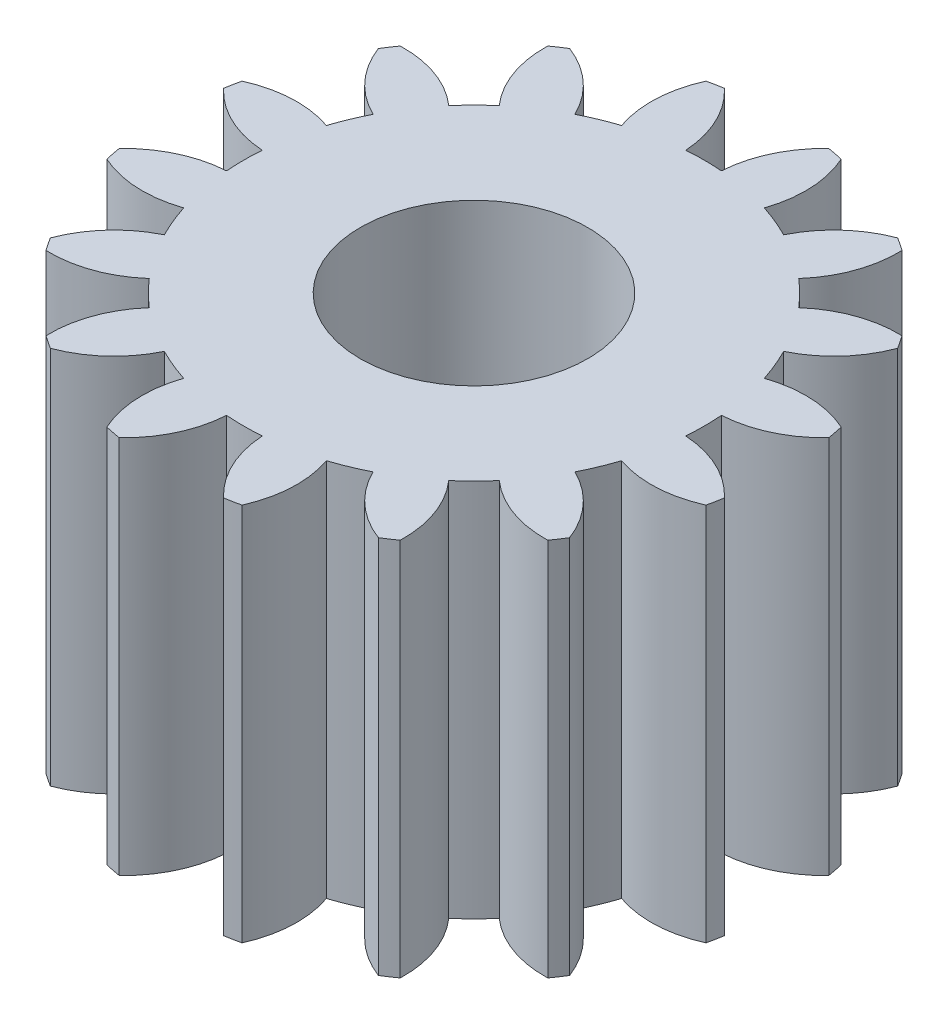
from build123d import *

# Parameters (mm, degrees)
BOSS_EXTRUDE1_DEPTH = 10
SKETCH2_R           = 3
CUT_EXTRUDE1_DEPTH  = 10


with BuildPart() as part:
    # Sketch1 → Boss-Extrude1 (new body)
    with BuildSketch(Plane(origin=(0, 0, 0), x_dir=(1, 0, 0), z_dir=(0, 1, 0))):
        with BuildLine():
            ThreePointArc((-7.982172642, 1.3765609), (-7.105660658, 0.739320543), (-6.05570223, 0.47111199))
            ThreePointArc((-6.05570223, 0.47111199), (-6.074, 0), (-6.05570223, -0.47111199))
            ThreePointArc((-6.05570223, -0.47111199), (-7.105660658, -0.739320543), (-7.982172642, -1.3765609))
            ThreePointArc((-7.982172642, -1.3765609), (-7.944360771, -1.580231608), (-7.901352979, -1.782868784))
            ThreePointArc((-7.901352979, -1.782868784), (-6.84770017, -2.036175492), (-5.775026098, -1.882166189))
            ThreePointArc((-5.775026098, -1.882166189), (-5.61164428, -2.324419168), (-5.414452591, -2.75266764))
            ThreePointArc((-5.414452591, -2.75266764), (-6.281848724, -3.402261728), (-6.847778879, -4.326421665))
            ThreePointArc((-6.847778879, -4.326421665), (-6.73490386, -4.500118887), (-6.617623951, -4.670872857))
            ThreePointArc((-6.617623951, -4.670872857), (-5.547239406, -4.501682267), (-4.615154594, -3.948901628))
            ThreePointArc((-4.615154594, -3.948901628), (-4.294966589, -4.294966589), (-3.948901628, -4.615154594))
            ThreePointArc((-3.948901628, -4.615154594), (-4.501682267, -5.547239406), (-4.670872857, -6.617623951))
            ThreePointArc((-4.670872857, -6.617623951), (-4.500118887, -6.73490386), (-4.326421665, -6.847778879))
            ThreePointArc((-4.326421665, -6.847778879), (-3.402261728, -6.281848724), (-2.75266764, -5.414452591))
            ThreePointArc((-2.75266764, -5.414452591), (-2.324419168, -5.61164428), (-1.882166189, -5.775026098))
            ThreePointArc((-1.882166189, -5.775026098), (-2.036175492, -6.84770017), (-1.782868784, -7.901352979))
            ThreePointArc((-1.782868784, -7.901352979), (-1.580231608, -7.944360771), (-1.3765609, -7.982172642))
            ThreePointArc((-1.3765609, -7.982172642), (-0.739320543, -7.105660658), (-0.47111199, -6.05570223))
            ThreePointArc((-0.47111199, -6.05570223), (0, -6.074), (0.47111199, -6.05570223))
            ThreePointArc((0.47111199, -6.05570223), (0.739320543, -7.105660658), (1.3765609, -7.982172642))
            ThreePointArc((1.3765609, -7.982172642), (1.580231608, -7.944360771), (1.782868784, -7.901352979))
            ThreePointArc((1.782868784, -7.901352979), (2.036175492, -6.84770017), (1.882166189, -5.775026098))
            ThreePointArc((1.882166189, -5.775026098), (2.324419168, -5.61164428), (2.75266764, -5.414452591))
            ThreePointArc((2.75266764, -5.414452591), (3.402261728, -6.281848724), (4.326421665, -6.847778879))
            ThreePointArc((4.326421665, -6.847778879), (4.500118887, -6.73490386), (4.670872857, -6.617623951))
            ThreePointArc((4.670872857, -6.617623951), (4.501682267, -5.547239406), (3.948901628, -4.615154594))
            ThreePointArc((3.948901628, -4.615154594), (4.294966589, -4.294966589), (4.615154594, -3.948901628))
            ThreePointArc((4.615154594, -3.948901628), (5.547239406, -4.501682267), (6.617623951, -4.670872857))
            ThreePointArc((6.617623951, -4.670872857), (6.73490386, -4.500118887), (6.847778879, -4.326421665))
            ThreePointArc((6.847778879, -4.326421665), (6.281848724, -3.402261728), (5.414452591, -2.75266764))
            ThreePointArc((5.414452591, -2.75266764), (5.61164428, -2.324419168), (5.775026098, -1.882166189))
            ThreePointArc((5.775026098, -1.882166189), (6.84770017, -2.036175492), (7.901352979, -1.782868784))
            ThreePointArc((7.901352979, -1.782868784), (7.944360771, -1.580231608), (7.982172642, -1.3765609))
            ThreePointArc((7.982172642, -1.3765609), (7.105660658, -0.739320543), (6.05570223, -0.47111199))
            ThreePointArc((6.05570223, -0.47111199), (6.074, 0), (6.05570223, 0.47111199))
            ThreePointArc((6.05570223, 0.47111199), (7.105660658, 0.739320543), (7.982172642, 1.3765609))
            ThreePointArc((7.982172642, 1.3765609), (7.944360771, 1.580231608), (7.901352979, 1.782868784))
            ThreePointArc((7.901352979, 1.782868784), (6.84770017, 2.036175492), (5.775026098, 1.882166189))
            ThreePointArc((5.775026098, 1.882166189), (5.61164428, 2.324419168), (5.414452591, 2.75266764))
            ThreePointArc((5.414452591, 2.75266764), (6.281848724, 3.402261728), (6.847778879, 4.326421665))
            ThreePointArc((6.847778879, 4.326421665), (6.73490386, 4.500118887), (6.617623951, 4.670872857))
            ThreePointArc((6.617623951, 4.670872857), (5.547239406, 4.501682267), (4.615154594, 3.948901628))
            ThreePointArc((4.615154594, 3.948901628), (4.294966589, 4.294966589), (3.948901628, 4.615154594))
            ThreePointArc((3.948901628, 4.615154594), (4.501682267, 5.547239406), (4.670872857, 6.617623951))
            ThreePointArc((4.670872857, 6.617623951), (4.500118887, 6.73490386), (4.326421665, 6.847778879))
            ThreePointArc((4.326421665, 6.847778879), (3.402261728, 6.281848724), (2.75266764, 5.414452591))
            ThreePointArc((2.75266764, 5.414452591), (2.324419168, 5.61164428), (1.882166189, 5.775026098))
            ThreePointArc((1.882166189, 5.775026098), (2.036175492, 6.84770017), (1.782868784, 7.901352979))
            ThreePointArc((1.782868784, 7.901352979), (1.580231608, 7.944360771), (1.3765609, 7.982172642))
            ThreePointArc((1.3765609, 7.982172642), (0.739320543, 7.105660658), (0.47111199, 6.05570223))
            ThreePointArc((0.47111199, 6.05570223), (0, 6.074), (-0.47111199, 6.05570223))
            ThreePointArc((-0.47111199, 6.05570223), (-0.739320543, 7.105660658), (-1.3765609, 7.982172642))
            ThreePointArc((-1.3765609, 7.982172642), (-1.580231608, 7.944360771), (-1.782868784, 7.901352979))
            ThreePointArc((-1.782868784, 7.901352979), (-2.036175492, 6.84770017), (-1.882166189, 5.775026098))
            ThreePointArc((-1.882166189, 5.775026098), (-2.324419168, 5.61164428), (-2.75266764, 5.414452591))
            ThreePointArc((-2.75266764, 5.414452591), (-3.402261728, 6.281848724), (-4.326421665, 6.847778879))
            ThreePointArc((-4.326421665, 6.847778879), (-4.500118887, 6.73490386), (-4.670872857, 6.617623951))
            ThreePointArc((-4.670872857, 6.617623951), (-4.501682267, 5.547239406), (-3.948901628, 4.615154594))
            ThreePointArc((-3.948901628, 4.615154594), (-4.294966589, 4.294966589), (-4.615154594, 3.948901628))
            ThreePointArc((-4.615154594, 3.948901628), (-5.547239406, 4.501682267), (-6.617623951, 4.670872857))
            ThreePointArc((-6.617623951, 4.670872857), (-6.73490386, 4.500118887), (-6.847778879, 4.326421665))
            ThreePointArc((-6.847778879, 4.326421665), (-6.281848724, 3.402261728), (-5.414452591, 2.75266764))
            ThreePointArc((-5.414452591, 2.75266764), (-5.61164428, 2.324419168), (-5.775026098, 1.882166189))
            ThreePointArc((-5.775026098, 1.882166189), (-6.84770017, 2.036175492), (-7.901352979, 1.782868784))
            ThreePointArc((-7.901352979, 1.782868784), (-7.944360771, 1.580231608), (-7.982172642, 1.3765609))
        make_face()
    extrude(amount=BOSS_EXTRUDE1_DEPTH)

    # Sketch2 → Cut-Extrude1 (cut)
    with BuildSketch(Plane(origin=(0, 10, 0), x_dir=(1, 0, 0), z_dir=(0, 1, 0))):
        Circle(SKETCH2_R)
    extrude(amount=-CUT_EXTRUDE1_DEPTH, mode=Mode.SUBTRACT)


solid = part.part
